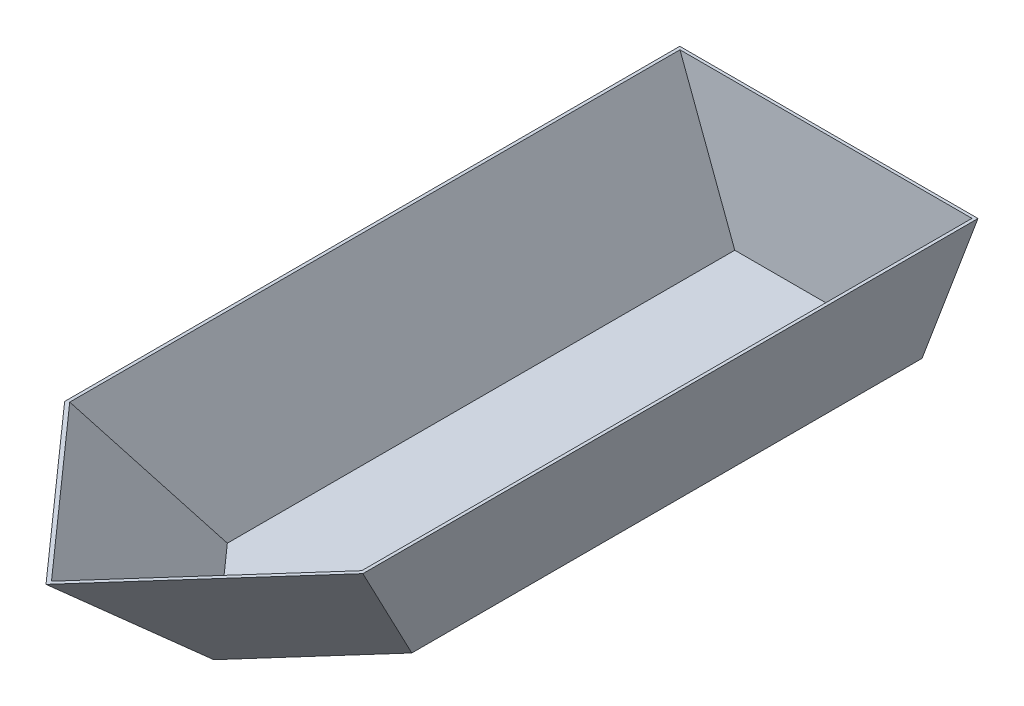
from build123d import *

# Parameters (mm, degrees)
BOSS_EXTRUDE1_DEPTH = 2133.6
CUT_EXTRUDE2_DEPTH  = 613.218203925
SHELL1_T            = -7.9375


with BuildPart() as part:
    # Sketch1 → Boss-Extrude1 (new body)
    with BuildSketch(Plane.XY):
        Polygon((0, 0), (508, 0), (660.4, 406.4), (-152.4, 406.4), align=None)
    extrude(amount=BOSS_EXTRUDE1_DEPTH)

    # Sketch13 → Cut-Extrude2 (cut, symmetric, along a direction that is not the sketch's normal)
    with BuildSketch(Plane(origin=(254, 0, 0), x_dir=(0, 0, -1), z_dir=(1, 0, 0))):
        Polygon((-2133.6, 0), (-3174.648587482, 0), (-3174.648587482, 406.4), (-2133.6, 406.4), (-1676.4, 0), align=None)
    cut_extrude2 = extrude(amount=CUT_EXTRUDE2_DEPTH, dir=(0.664363839, 0, 0.747409319), both=True, mode=Mode.SUBTRACT)

    # Mirror1: Cut-Extrude2 across plane
    add(cut_extrude2.mirror(Plane(origin=(254, 0, 0), x_dir=(0, 0, 1), z_dir=(1, 0, 0))), mode=Mode.SUBTRACT)

    # Shell1
    shell1_openings = [part.faces().sort_by_distance(p)[0] for p in [
        (254, 406.4, 1097.28),
    ]]
    offset(amount=SHELL1_T, openings=shell1_openings, kind=Kind.INTERSECTION)


solid = part.part
